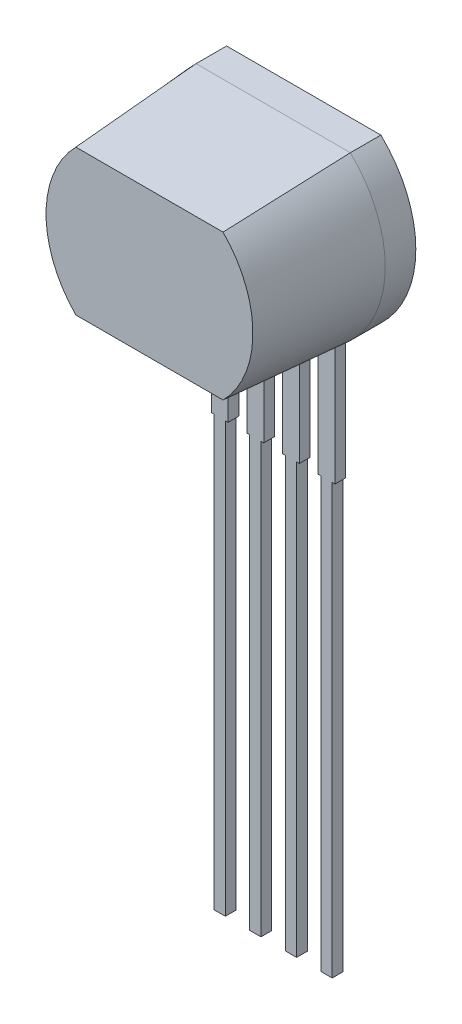
from build123d import *

# Parameters (mm, degrees)
BOSS_EXTRUDE1_DEPTH           = 4.41
BOSS_EXTRUDE1_DRAFT           = 4
BOSS_EXTRUDE1_OTHER_WAY_DEPTH = 1.09
BOSS_EXTRUDE2_DEPTH           = 0.38
BOSS_EXTRUDE2_2_DEPTH         = 0.38
BOSS_EXTRUDE2_3_DEPTH         = 0.38
BOSS_EXTRUDE2_4_DEPTH         = 0.38
CUT_EXTRUDE1_DEPTH            = 0.01


with BuildPart() as part:
    # Sketch1 → Boss-Extrude1 (with draft: the straight prism first)
    with BuildSketch(Plane.XY):
        with BuildLine():
            ThreePointArc((-2.75, 2.9), (-3.995004537, 0), (-2.75, -2.9))
            Line((-2.75, -2.9), (2.75, -2.9))
            ThreePointArc((2.75, -2.9), (3.995004537, 0), (2.75, 2.9))
            Line((2.75, 2.9), (-2.75, 2.9))
        make_face()
    extrude(amount=BOSS_EXTRUDE1_DEPTH)
    # Boss-Extrude1: the draft: its side faces are tilted about the plane it starts from
    boss_extrude1_sides = [part.faces().sort_by_distance(p)[0] for p in [
        (-3.995004537, 0, 2.205),
        (0, -2.9, 2.205),
        (3.995004537, 0, 2.205),
        (0, 2.9, 2.205),
    ]]
    draft(boss_extrude1_sides, Plane.XY, BOSS_EXTRUDE1_DRAFT)

    # Sketch1 → Boss-Extrude1 other way (add)
    with BuildSketch(Plane.XY):
        with BuildLine():
            ThreePointArc((-2.75, 2.9), (-3.995004537, 0), (-2.75, -2.9))
            Line((-2.75, -2.9), (2.75, -2.9))
            ThreePointArc((2.75, -2.9), (3.995004537, 0), (2.75, 2.9))
            Line((2.75, 2.9), (-2.75, 2.9))
        make_face()
    extrude(amount=-BOSS_EXTRUDE1_OTHER_WAY_DEPTH)

    # Sketch3 → Cut-Extrude1 (cut)
    with BuildSketch(Plane(origin=(0, 0, -1.09), x_dir=(-1, 0, 0), z_dir=(0, 0, -1))):
        Polygon((0.016740004, 2.333243647), (0.505201543, 1.274910314), (0.401954681, 1.274910314), (0.245494344, 1.614119715), (-0.234274953, 1.614119715), (-0.395187413, 1.274910314), (-0.498858287, 1.274910314), (0.003171628, 2.333243647), align=None)
        Polygon((0.008895787, 2.12696193), (-0.182757525, 1.722666724), (0.195460958, 1.722666724), align=None, mode=Mode.SUBTRACT)
        Polygon((-2.073635561, 0.79375), (-1.707289407, 0), (-1.784724553, 0), (-1.902069806, 0.254407051), (-2.261896779, 0.254407051), (-2.382581124, 0), (-2.460334279, 0), (-2.083811843, 0.79375), align=None)
        Polygon((-2.079518724, 0.639038712), (-2.223258708, 0.335817308), (-1.939594846, 0.335817308), align=None, mode=Mode.SUBTRACT)
        Polygon((-1.656407997, 0.712339744), (-1.656407997, 0.79375), (-1.239180433, 0.79375), (-1.239180433, 0.712339744), (-1.412177228, 0.712339744), (-1.412177228, 0), (-1.483411202, 0), (-1.483411202, 0.712339744), align=None)
        with BuildLine():
            Line((-1.198475305, 0.153121244), (-1.131375445, 0.193349359))
            add(Edge.make_bspline(
                [(-1.131375445, 0.193349359), (-1.125134702, 0.182902615), (-1.113177679, 0.162887055), (-1.093231567, 0.135841035), (-1.072563925, 0.112853546), (-1.051021701, 0.094058316), (-1.028736388, 0.0792608), (-1.005562504, 0.068782794), (-0.981578143, 0.062247743), (-0.965255509, 0.061453973), (-0.957106615, 0.061057692)],
                knots=[0, 0, 0, 0, 1.272034388, 2.437168799, 3.508375237, 4.49857839, 5.41946034, 6.295179144, 7.148887113, 8, 8, 8, 8], degree=3))
            add(Edge.make_bspline(
                [(-0.957106615, 0.061057692), (-0.950147273, 0.06125152), (-0.936350362, 0.061635783), (-0.916038925, 0.065328037), (-0.896312695, 0.07100043), (-0.877578236, 0.079124106), (-0.860094052, 0.088952655), (-0.844761819, 0.10082402), (-0.831507076, 0.114115071), (-0.820664651, 0.128942923), (-0.812346143, 0.144889847), (-0.805952585, 0.161258322), (-0.802404506, 0.17830548), (-0.801870028, 0.18978321), (-0.801600305, 0.195575421)],
                knots=[0, 0, 0, 0, 1.095163259, 2.171163733, 3.241058638, 4.321873601, 5.38011039, 6.391990106, 7.366004449, 8.327778327, 9.272591725, 10.192022065, 11.087607919, 12, 12, 12, 12], degree=3))
            add(Edge.make_bspline(
                [(-0.801600305, 0.195575421), (-0.801934657, 0.202184149), (-0.802614347, 0.215618728), (-0.808359165, 0.235439721), (-0.817396405, 0.255055), (-0.825733647, 0.267188323), (-0.830062094, 0.27348758)],
                knots=[0, 0, 0, 0, 0.938893495, 1.908633276, 2.914225137, 4, 4, 4, 4], degree=3))
            add(Edge.make_bspline(
                [(-0.830062094, 0.27348758), (-0.833615965, 0.278033913), (-0.841076874, 0.287578371), (-0.853903309, 0.301785416), (-0.868954196, 0.31643995), (-0.885714467, 0.332101558), (-0.904794649, 0.348041826), (-0.925597139, 0.365020882), (-0.94865305, 0.382393025), (-0.964822757, 0.394043589), (-0.97316606, 0.400055088)],
                knots=[0, 0, 0, 0, 0.722233717, 1.516239348, 2.393582979, 3.351407094, 4.387010283, 5.505090956, 6.712668013, 8, 8, 8, 8], degree=3))
            add(Edge.make_bspline(
                [(-0.97316606, 0.400055088), (-0.981517216, 0.406003357), (-0.997483991, 0.417375994), (-1.019812991, 0.434254359), (-1.039780217, 0.449685736), (-1.057296923, 0.463815396), (-1.072355403, 0.476645255), (-1.085074319, 0.488052109), (-1.095129671, 0.498344452), (-1.100721204, 0.505021328), (-1.103231665, 0.508019081)],
                knots=[0, 0, 0, 0, 1.452282411, 2.77665338, 3.964542531, 5.026858415, 5.96415736, 6.766646006, 7.446254459, 8, 8, 8, 8], degree=3))
            add(Edge.make_bspline(
                [(-1.103231665, 0.508019081), (-1.106740617, 0.512691101), (-1.113641443, 0.521879257), (-1.122750519, 0.536240431), (-1.130492793, 0.550941421), (-1.136562108, 0.566021733), (-1.141673, 0.581269655), (-1.145110602, 0.596884134), (-1.147263116, 0.612795106), (-1.147483548, 0.623502453), (-1.147593894, 0.62886243)],
                knots=[0, 0, 0, 0, 1.068054152, 2.10047183, 3.106115577, 4.101338837, 5.06977816, 6.043150881, 7.020423561, 8, 8, 8, 8], degree=3))
            add(Edge.make_bspline(
                [(-1.147593894, 0.62886243), (-1.147297892, 0.637260254), (-1.146712213, 0.653876404), (-1.141759096, 0.678149467), (-1.133941136, 0.701323887), (-1.122988545, 0.72317023), (-1.108869467, 0.743119658), (-1.092530469, 0.761401645), (-1.07306965, 0.776770592), (-1.05171718, 0.790199041), (-1.028345467, 0.800709634), (-1.003854673, 0.808638285), (-0.978205873, 0.813130742), (-0.960833376, 0.81377544), (-0.952018474, 0.814102564)],
                knots=[0, 0, 0, 0, 1.005424448, 1.989358655, 2.955360095, 3.929531133, 4.905563448, 5.876582895, 6.856512386, 7.866279853, 8.892233794, 9.918561126, 10.94386622, 12, 12, 12, 12], degree=3))
            add(Edge.make_bspline(
                [(-0.952018474, 0.814102564), (-0.942664901, 0.81377995), (-0.92406363, 0.813138373), (-0.896702112, 0.807560004), (-0.870358521, 0.798329673), (-0.849166923, 0.787854745), (-0.832581457, 0.777392799), (-0.819932998, 0.767863303), (-0.807115648, 0.75689252), (-0.794026018, 0.744451226), (-0.780885904, 0.730425267), (-0.767500228, 0.7149107), (-0.753837689, 0.698002338), (-0.745048413, 0.685931782), (-0.740542612, 0.67974384)],
                knots=[0, 0, 0, 0, 1.286793592, 2.559021753, 3.825965368, 5.121522368, 5.803751409, 6.523245864, 7.299691795, 8.125521123, 9.008227632, 9.944561021, 10.946284179, 12, 12, 12, 12], degree=3))
            Line((-0.740542612, 0.67974384), (-0.804939397, 0.630929487))
            add(Edge.make_bspline(
                [(-0.804939397, 0.630929487), (-0.80882785, 0.635938887), (-0.8163161, 0.645585819), (-0.827684752, 0.659095742), (-0.83840007, 0.671436622), (-0.848957036, 0.682155678), (-0.858798091, 0.691839912), (-0.868349635, 0.700131142), (-0.877474211, 0.707110608), (-0.888976082, 0.714559058), (-0.90342635, 0.721942408), (-0.9215657, 0.728190145), (-0.940521873, 0.731944597), (-0.953432701, 0.732441005), (-0.959968694, 0.732692308)],
                knots=[0, 0, 0, 0, 1.181633172, 2.275549214, 3.290209073, 4.226197932, 5.078386478, 5.862611352, 6.581680152, 7.217281963, 8.414376989, 9.595101626, 10.782541182, 12, 12, 12, 12], degree=3))
            add(Edge.make_bspline(
                [(-0.959968694, 0.732692308), (-0.968168477, 0.732417511), (-0.983980985, 0.731887593), (-1.006430557, 0.726100025), (-1.026635786, 0.716987353), (-1.043996814, 0.70421592), (-1.05845145, 0.689084552), (-1.06890751, 0.671672205), (-1.075200851, 0.652444767), (-1.07596881, 0.639032284), (-1.07635992, 0.632201522)],
                knots=[0, 0, 0, 0, 1.14458467, 2.207223713, 3.21896685, 4.227309161, 5.202851033, 6.127160689, 7.046193047, 8, 8, 8, 8], degree=3))
            add(Edge.make_bspline(
                [(-1.07635992, 0.632201522), (-1.076270765, 0.627948955), (-1.076092308, 0.619436866), (-1.07360338, 0.606861276), (-1.070405854, 0.594317454), (-1.065338864, 0.581861797), (-1.05834359, 0.569276469), (-1.049157595, 0.556344754), (-1.037588504, 0.54295267), (-1.028726396, 0.534242426), (-1.02404747, 0.52964368)],
                knots=[0, 0, 0, 0, 0.858281714, 1.717966888, 2.583508476, 3.4729293, 4.427298488, 5.488583878, 6.674047936, 8, 8, 8, 8], degree=3))
            add(Edge.make_bspline(
                [(-1.02404747, 0.52964368), (-1.02230998, 0.52809314), (-1.018182102, 0.524409413), (-1.010635598, 0.518378663), (-1.000669999, 0.510939463), (-0.988545535, 0.501734839), (-0.974038651, 0.491057436), (-0.957147752, 0.479043778), (-0.938061119, 0.465303861), (-0.924517041, 0.455697776), (-0.917355513, 0.45061849)],
                knots=[0, 0, 0, 0, 0.420754252, 0.999615792, 1.744751191, 2.668019286, 3.750313428, 4.999500688, 6.413464383, 8, 8, 8, 8], degree=3))
            add(Edge.make_bspline(
                [(-0.917355513, 0.45061849), (-0.908740851, 0.444349824), (-0.892059751, 0.432211422), (-0.868324907, 0.413974295), (-0.846804347, 0.396138104), (-0.827422513, 0.378816754), (-0.809987928, 0.362141633), (-0.794694017, 0.345912126), (-0.781384943, 0.330244505), (-0.767056799, 0.31015751), (-0.752416007, 0.285487515), (-0.739842665, 0.255261914), (-0.731914612, 0.22491882), (-0.730877857, 0.204524698), (-0.73036633, 0.19446239)],
                knots=[0, 0, 0, 0, 1.163667725, 2.253281268, 3.268753668, 4.215851969, 5.092017293, 5.902905408, 6.650798638, 7.335211899, 8.59617414, 9.77448103, 10.901945474, 12, 12, 12, 12], degree=3))
            add(Edge.make_bspline(
                [(-0.73036633, 0.19446239), (-0.73051536, 0.187346225), (-0.730810525, 0.173252086), (-0.734203446, 0.152556738), (-0.739174513, 0.132456523), (-0.746666886, 0.113199896), (-0.755811602, 0.094434566), (-0.767415376, 0.076652774), (-0.780865512, 0.059460966), (-0.796294598, 0.043317567), (-0.813177865, 0.028497983), (-0.831022203, 0.015315142), (-0.849856818, 0.004323219), (-0.869579537, -0.004646347), (-0.890194888, -0.011661627), (-0.911695939, -0.016744545), (-0.934118132, -0.019864144), (-0.949358241, -0.02018794), (-0.957106615, -0.020352564)],
                knots=[0, 0, 0, 0, 0.983748083, 1.948392443, 2.894712957, 3.844097841, 4.80183111, 5.778335162, 6.776009319, 7.81870978, 8.863265674, 9.881300176, 10.883814829, 11.87499822, 12.874611388, 13.892143829, 14.928324115, 16, 16, 16, 16], degree=3))
            add(Edge.make_bspline(
                [(-0.957106615, -0.020352564), (-0.963101773, -0.020236635), (-0.975016586, -0.020006238), (-0.992639987, -0.017969412), (-1.009907358, -0.015087622), (-1.026602025, -0.010512432), (-1.042939081, -0.004961403), (-1.058847472, 0.00187354), (-1.074334907, 0.010064406), (-1.089488181, 0.019429527), (-1.104268752, 0.030328337), (-1.118537989, 0.043022327), (-1.132764072, 0.057161397), (-1.146527106, 0.073129507), (-1.16010548, 0.090668679), (-1.173231477, 0.109943012), (-1.186176795, 0.130847519), (-1.194299231, 0.145557993), (-1.198475305, 0.153121244)],
                knots=[0, 0, 0, 0, 0.915332311, 1.819136955, 2.706846663, 3.586547465, 4.459518054, 5.340707479, 6.227863349, 7.133153174, 8.059268498, 9.028702269, 10.047606654, 11.120612155, 12.245963614, 13.433783089, 14.680604001, 16, 16, 16, 16], degree=3))
        make_face()
        with BuildLine():
            Line((-0.272433638, 0.814102564), (-0.217577118, 0.77101237))
            Line((-0.217577118, 0.77101237), (-0.42730393, 0.450300481))
            add(Edge.make_bspline(
                [(-0.42730393, 0.450300481), (-0.413340671, 0.452526124), (-0.386103755, 0.456867493), (-0.358534346, 0.45758367), (-0.345098652, 0.457932692)],
                knots=[0, 0, 0, 0, 1.025318673, 2, 2, 2, 2], degree=3))
            add(Edge.make_bspline(
                [(-0.345098652, 0.457932692), (-0.337031318, 0.45771586), (-0.321151011, 0.457289032), (-0.297835897, 0.454004301), (-0.275431978, 0.448827892), (-0.254032112, 0.441282219), (-0.233559489, 0.431643293), (-0.213896625, 0.420091085), (-0.195413133, 0.406029082), (-0.177870991, 0.39032078), (-0.161944488, 0.372922464), (-0.147843847, 0.354461803), (-0.135999557, 0.334958032), (-0.126389757, 0.314421028), (-0.1189274, 0.29288245), (-0.113487345, 0.270369854), (-0.110271616, 0.246867717), (-0.109834942, 0.230884273), (-0.109613125, 0.222765174)],
                knots=[0, 0, 0, 0, 1.04369286, 2.054478336, 3.041073146, 4.015093852, 4.984733326, 5.965804835, 6.960378782, 7.985147595, 9.009457201, 10.008161701, 10.986880575, 11.956520048, 12.937015923, 13.931873656, 14.949455224, 16, 16, 16, 16], degree=3))
            add(Edge.make_bspline(
                [(-0.109613125, 0.222765174), (-0.109935865, 0.211657277), (-0.110570941, 0.189799564), (-0.116899123, 0.157964133), (-0.126732471, 0.127635509), (-0.140788089, 0.099297914), (-0.158246594, 0.072990189), (-0.179536691, 0.049679914), (-0.203903339, 0.028890459), (-0.231454809, 0.011505833), (-0.261105446, -0.002691645), (-0.292254917, -0.01288912), (-0.324600716, -0.019167335), (-0.346554618, -0.019954418), (-0.35766, -0.020352564)],
                knots=[0, 0, 0, 0, 1.031375318, 2.029502543, 3.004789286, 3.987476834, 4.960371455, 5.9300674, 6.912260825, 7.929083631, 8.949397511, 9.960523116, 10.96833055, 12, 12, 12, 12], degree=3))
            add(Edge.make_bspline(
                [(-0.35766, -0.020352564), (-0.368340859, -0.020005989), (-0.389497771, -0.019319484), (-0.420620208, -0.013203995), (-0.450524856, -0.003291848), (-0.479002198, 0.01036389), (-0.505382051, 0.027612731), (-0.528982651, 0.048377748), (-0.549686321, 0.072215073), (-0.56691628, 0.099121009), (-0.5805821, 0.12803391), (-0.590830529, 0.158182158), (-0.59681682, 0.189455904), (-0.597653332, 0.210656091), (-0.598074664, 0.221334135)],
                knots=[0, 0, 0, 0, 1.012016664, 2.004627821, 2.994792927, 3.992885782, 4.990978636, 5.973936114, 6.964471063, 7.975201453, 8.993600317, 9.990122807, 10.98767138, 12, 12, 12, 12], degree=3))
            add(Edge.make_bspline(
                [(-0.598074664, 0.221334135), (-0.597806729, 0.229508531), (-0.597259657, 0.246199087), (-0.593439817, 0.271477536), (-0.587301908, 0.297342692), (-0.580427977, 0.319285161), (-0.573165026, 0.337260542), (-0.567120611, 0.351752941), (-0.559597223, 0.366666613), (-0.551575045, 0.382512955), (-0.542331969, 0.39888358), (-0.532281813, 0.416052091), (-0.521146714, 0.433745442), (-0.513340713, 0.44575243), (-0.509350205, 0.451890525)],
                knots=[0, 0, 0, 0, 1.173818275, 2.396712641, 3.66331629, 4.989737886, 5.693666774, 6.447286557, 7.243889047, 8.091586357, 8.998013824, 9.943181721, 10.948533338, 12, 12, 12, 12], degree=3))
            Line((-0.509350205, 0.451890525), (-0.272433638, 0.814102564))
        make_face()
        with BuildLine():
            add(Edge.make_bspline(
                [(-0.360045066, 0.376522436), (-0.366091683, 0.376345987), (-0.377902481, 0.37600133), (-0.395230591, 0.373999889), (-0.411630203, 0.370230922), (-0.427318589, 0.365430701), (-0.442002443, 0.358830543), (-0.455788483, 0.35081326), (-0.468730022, 0.341374171), (-0.480691506, 0.330647), (-0.491536322, 0.318902214), (-0.500875615, 0.306322519), (-0.508931587, 0.293211083), (-0.515481571, 0.279458357), (-0.520581999, 0.265069598), (-0.524271406, 0.250110982), (-0.526324668, 0.234482202), (-0.526666259, 0.223883938), (-0.526840689, 0.218472055)],
                knots=[0, 0, 0, 0, 1.129588631, 2.206414736, 3.251139165, 4.268635594, 5.265702196, 6.250456724, 7.242448911, 8.251968645, 9.246821453, 10.222880186, 11.173611482, 12.116736599, 13.062300278, 14.020270554, 14.989073742, 16, 16, 16, 16], degree=3))
            add(Edge.make_bspline(
                [(-0.526840689, 0.218472055), (-0.526698639, 0.213108578), (-0.526420101, 0.202591597), (-0.523890914, 0.187093247), (-0.520027601, 0.172178705), (-0.514280761, 0.157924861), (-0.507425735, 0.144114446), (-0.498375777, 0.131247693), (-0.488348042, 0.118543142), (-0.476361525, 0.106976737), (-0.463497476, 0.096214252), (-0.449753989, 0.086807123), (-0.435430213, 0.078759366), (-0.420332765, 0.072452206), (-0.404675846, 0.067275984), (-0.388329006, 0.06363347), (-0.371280876, 0.061574137), (-0.359732508, 0.0612321), (-0.353843894, 0.061057692)],
                knots=[0, 0, 0, 0, 0.989467248, 1.94019797, 2.891935182, 3.827694429, 4.772920941, 5.730924762, 6.725747692, 7.756678648, 8.79901574, 9.819492441, 10.826891316, 11.826466727, 12.835195252, 13.867842842, 14.912794438, 16, 16, 16, 16], degree=3))
            add(Edge.make_bspline(
                [(-0.353843894, 0.061057692), (-0.34795529, 0.061232114), (-0.336406941, 0.061574177), (-0.319358674, 0.063633316), (-0.303012341, 0.067276549), (-0.28735358, 0.072450159), (-0.272262934, 0.07876696), (-0.257951684, 0.086757056), (-0.24433817, 0.096272104), (-0.231465677, 0.106958344), (-0.219529052, 0.118608973), (-0.209260812, 0.131134285), (-0.200488007, 0.144218437), (-0.193359182, 0.157870458), (-0.18767564, 0.172187324), (-0.183792735, 0.187090938), (-0.181268772, 0.202592201), (-0.180989515, 0.213108782), (-0.1808471, 0.218472055)],
                knots=[0, 0, 0, 0, 1.087397944, 2.132534446, 3.165364764, 4.174271784, 5.174024072, 6.181601208, 7.194203697, 8.236725232, 9.267838612, 10.269026844, 11.221737037, 12.171628256, 13.107553087, 14.05945871, 15.010357665, 16, 16, 16, 16], degree=3))
            add(Edge.make_bspline(
                [(-0.1808471, 0.218472055), (-0.180971898, 0.223890998), (-0.181216837, 0.23452662), (-0.18398724, 0.250103991), (-0.187829528, 0.2651456), (-0.193631394, 0.279556914), (-0.201168968, 0.293281062), (-0.210350026, 0.306387371), (-0.220970984, 0.318976325), (-0.233239533, 0.330670033), (-0.246594997, 0.341362317), (-0.260795317, 0.350801038), (-0.27565159, 0.358766881), (-0.291148752, 0.365413313), (-0.30746437, 0.370209711), (-0.324335036, 0.373986429), (-0.341976525, 0.375996208), (-0.353945506, 0.376344792), (-0.360045066, 0.376522436)],
                knots=[0, 0, 0, 0, 0.978206639, 1.919901502, 2.851605144, 3.780102724, 4.718870031, 5.675451981, 6.667674623, 7.690630536, 8.733308323, 9.756129687, 10.767539656, 11.776269907, 12.797430371, 13.836405707, 14.897401972, 16, 16, 16, 16], degree=3))
        make_face(mode=Mode.SUBTRACT)
        with BuildLine():
            add(Edge.make_bspline(
                [(-0.028202869, 0.396556991), (-0.028128479, 0.409279077), (-0.027983976, 0.433991913), (-0.026376423, 0.470002002), (-0.023705944, 0.503784067), (-0.020046218, 0.535339727), (-0.015592605, 0.564677127), (-0.009647307, 0.591717866), (-0.002886189, 0.616587099), (0.004949812, 0.63936592), (0.013791686, 0.660361221), (0.02341517, 0.679961222), (0.034202186, 0.698136267), (0.045536236, 0.715176445), (0.057876116, 0.730802818), (0.070870663, 0.745236065), (0.085027053, 0.75814261), (0.099864057, 0.769900611), (0.115516005, 0.780207902), (0.131536752, 0.789286755), (0.148036571, 0.797042796), (0.165060509, 0.803141163), (0.182455553, 0.808178266), (0.200282513, 0.811622902), (0.218570822, 0.813790272), (0.230915094, 0.813997479), (0.237175487, 0.814102564)],
                knots=[0, 0, 0, 0, 1.646270934, 3.197905019, 4.663502075, 6.030701355, 7.308322542, 8.50163776, 9.611534131, 10.641858119, 11.616356847, 12.558055219, 13.465016945, 14.349605745, 15.204443733, 16.039544428, 16.859896111, 17.680448484, 18.487036065, 19.28249412, 20.06191084, 20.843045899, 21.620316918, 22.403196591, 23.190181807, 24, 24, 24, 24], degree=3))
            add(Edge.make_bspline(
                [(0.237175487, 0.814102564), (0.243488175, 0.813991935), (0.256042127, 0.813771927), (0.274602355, 0.81165739), (0.292733801, 0.808148761), (0.310359165, 0.803177397), (0.327623224, 0.797009806), (0.344390945, 0.789279335), (0.36076648, 0.780280734), (0.376489599, 0.769707105), (0.391732913, 0.757918267), (0.406122005, 0.744591734), (0.419658183, 0.729862065), (0.432511333, 0.713886857), (0.444316798, 0.696359703), (0.455559345, 0.67758545), (0.465622289, 0.657235772), (0.475313902, 0.635650201), (0.483679344, 0.612231479), (0.491223653, 0.587111613), (0.497319419, 0.559993896), (0.502396986, 0.531020605), (0.506330561, 0.500085336), (0.509195464, 0.467254404), (0.510708824, 0.432506208), (0.510993826, 0.408748625), (0.51114008, 0.396556991)],
                knots=[0, 0, 0, 0, 0.810914788, 1.612654377, 2.396697861, 3.181598691, 3.963628158, 4.749916497, 5.551656086, 6.361998678, 7.18212741, 8.025565596, 8.878627764, 9.750805457, 10.657531673, 11.591944965, 12.560506719, 13.57287815, 14.630710178, 15.753379473, 16.941251878, 18.199788006, 19.531962791, 20.947069417, 22.433333509, 24, 24, 24, 24], degree=3))
            add(Edge.make_bspline(
                [(0.51114008, 0.396556991), (0.51099231, 0.384418533), (0.510704386, 0.360767244), (0.509212429, 0.326175398), (0.506273597, 0.293518698), (0.502597403, 0.262718826), (0.497505845, 0.233903973), (0.491245388, 0.206974428), (0.484294333, 0.181813898), (0.475713942, 0.158628503), (0.466322584, 0.137094809), (0.456104709, 0.116986366), (0.445157802, 0.098125439), (0.433231426, 0.080662996), (0.420519313, 0.064475337), (0.406749386, 0.049848197), (0.392309807, 0.036429134), (0.377021634, 0.024488497), (0.3610533, 0.014037122), (0.344734009, 0.004690409), (0.327774206, -0.002846291), (0.310558233, -0.009317631), (0.292839836, -0.014261662), (0.274641101, -0.017680197), (0.256054597, -0.020077741), (0.243490314, -0.020260639), (0.237175487, -0.020352564)],
                knots=[0, 0, 0, 0, 1.561518951, 3.042555995, 4.452378317, 5.7783523, 7.031515105, 8.214008947, 9.334062868, 10.386615937, 11.391082383, 12.354592575, 13.286541444, 14.194233754, 15.072674879, 15.931287219, 16.775624067, 17.606195743, 18.42308326, 19.229000347, 20.022332153, 20.807536673, 21.593273796, 22.3848459, 23.188221202, 24, 24, 24, 24], degree=3))
            add(Edge.make_bspline(
                [(0.237175487, -0.020352564), (0.230915268, -0.020246801), (0.218571338, -0.020038258), (0.200280521, -0.017880679), (0.182527181, -0.014411878), (0.165223713, -0.009554898), (0.148281343, -0.003609748), (0.131930935, 0.00413582), (0.115990692, 0.013056225), (0.100503143, 0.023215187), (0.085759314, 0.034854211), (0.071676237, 0.047727541), (0.058607706, 0.062156422), (0.046444259, 0.077913022), (0.034884064, 0.094852382), (0.024250224, 0.113205781), (0.014414334, 0.132900445), (0.005423757, 0.154063614), (-0.002547458, 0.177004106), (-0.009588634, 0.201984366), (-0.015148095, 0.229224877), (-0.01990673, 0.258506851), (-0.023744938, 0.289956117), (-0.026365294, 0.323589749), (-0.027984842, 0.359386788), (-0.028128867, 0.383940826), (-0.028202869, 0.396556991)],
                knots=[0, 0, 0, 0, 0.810891512, 1.598919785, 2.382837074, 3.152667961, 3.926044502, 4.706494248, 5.493654104, 6.291793342, 7.103789334, 7.925228297, 8.761435821, 9.622817696, 10.50288917, 11.416980706, 12.369136599, 13.353924996, 14.394355917, 15.514179734, 16.714354668, 17.994756427, 19.357759367, 20.818452758, 22.365282078, 24, 24, 24, 24], degree=3))
        make_face()
        with BuildLine():
            add(Edge.make_bspline(
                [(0.043031106, 0.396875), (0.043058194, 0.386273063), (0.043110769, 0.365696785), (0.044484228, 0.335796617), (0.046355263, 0.307908703), (0.048768557, 0.281997633), (0.05235244, 0.258151112), (0.056368087, 0.236205131), (0.061254886, 0.216275829), (0.067036792, 0.19822645), (0.073622444, 0.181750679), (0.080812881, 0.166419689), (0.088537366, 0.152052375), (0.097182245, 0.138777789), (0.106597268, 0.126552641), (0.116569775, 0.115160552), (0.127471951, 0.105001237), (0.142554049, 0.092816754), (0.162465036, 0.080225807), (0.187552175, 0.069261605), (0.213330555, 0.062371298), (0.230827357, 0.061495053), (0.239560553, 0.061057692)],
                knots=[0, 0, 0, 0, 1.459021318, 2.831673884, 4.118529203, 5.306027144, 6.411944654, 7.436330062, 8.375795394, 9.233974572, 10.042671642, 10.816086306, 11.563610507, 12.285937304, 12.993564865, 13.685989202, 14.367179055, 15.041617293, 16.353048772, 17.594441528, 18.799311195, 20, 20, 20, 20], degree=3))
            add(Edge.make_bspline(
                [(0.239560553, 0.061057692), (0.248350239, 0.061420046), (0.265911464, 0.062144006), (0.291568593, 0.069128719), (0.316476529, 0.079667347), (0.335996415, 0.092128656), (0.350846921, 0.103995974), (0.361487024, 0.114113939), (0.371252881, 0.125443216), (0.38051528, 0.137666806), (0.389010464, 0.151018245), (0.396735497, 0.165433329), (0.403784756, 0.180952089), (0.407800914, 0.191785583), (0.409854273, 0.197324469)],
                knots=[0, 0, 0, 0, 1.353760809, 2.704726607, 4.075137775, 5.516104923, 6.260822281, 7.007110065, 7.778089737, 8.566572457, 9.372053459, 10.217411131, 11.088608312, 12, 12, 12, 12], degree=3))
            add(Edge.make_bspline(
                [(0.409854273, 0.197324469), (0.412247263, 0.204406928), (0.417106059, 0.218787357), (0.423368015, 0.241094828), (0.428299561, 0.26449974), (0.432736253, 0.288862222), (0.435764535, 0.31436194), (0.438201986, 0.340919995), (0.439637695, 0.368556411), (0.439815665, 0.387333132), (0.439906106, 0.396875)],
                knots=[0, 0, 0, 0, 0.884706709, 1.796334032, 2.740027952, 3.714592787, 4.726048262, 5.777819803, 6.87074269, 8, 8, 8, 8], degree=3))
            add(Edge.make_bspline(
                [(0.439906106, 0.396875), (0.439781331, 0.406415324), (0.439537244, 0.425078239), (0.43860425, 0.45241004), (0.436194975, 0.478369693), (0.433519104, 0.503069033), (0.429573662, 0.526371333), (0.42531966, 0.54847167), (0.419604385, 0.569096249), (0.413499364, 0.588567976), (0.406512007, 0.606665624), (0.398820403, 0.623473572), (0.390605825, 0.639072965), (0.381683567, 0.653421004), (0.372159546, 0.666581955), (0.361782388, 0.678291944), (0.350963718, 0.688913899), (0.335810534, 0.701038446), (0.315972615, 0.71340092), (0.291287977, 0.724777798), (0.265599813, 0.731311107), (0.248234048, 0.732232239), (0.239560553, 0.732692308)],
                knots=[0, 0, 0, 0, 1.31362396, 2.569729283, 3.763502607, 4.902122613, 5.988968491, 7.01645872, 7.998833611, 8.933434873, 9.825090667, 10.667526885, 11.477055099, 12.250526234, 12.991942729, 13.710640831, 14.402115721, 15.076753259, 16.378508321, 17.609869233, 18.806226677, 20, 20, 20, 20], degree=3))
            add(Edge.make_bspline(
                [(0.239560553, 0.732692308), (0.230781543, 0.732231605), (0.213207532, 0.731309359), (0.18725237, 0.724802139), (0.162372991, 0.713459913), (0.14258753, 0.7009975), (0.127423779, 0.689127919), (0.116746097, 0.678834919), (0.106734375, 0.667575858), (0.097511522, 0.655238281), (0.088873417, 0.641979171), (0.080940223, 0.627694219), (0.073792543, 0.612311034), (0.067196585, 0.595842664), (0.061397042, 0.577794843), (0.056613233, 0.557890089), (0.052193847, 0.53601391), (0.049065278, 0.512038236), (0.046284033, 0.486120676), (0.044496656, 0.458163141), (0.043106174, 0.428212826), (0.04305663, 0.40753016), (0.043031106, 0.396875)],
                knots=[0, 0, 0, 0, 1.207732386, 2.417664972, 3.655092373, 4.956220595, 5.625982001, 6.301752483, 6.994047911, 7.697131622, 8.419323945, 9.170223765, 9.943494443, 10.752040957, 11.610060368, 12.549350801, 13.567764191, 14.679664412, 15.874934091, 17.154273443, 18.533957287, 20, 20, 20, 20], degree=3))
        make_face(mode=Mode.SUBTRACT)
        with BuildLine():
            Line((1.081011875, 0.79375), (1.081011875, 0.712339744))
            Line((1.081011875, 0.712339744), (0.811022392, 0.712339744))
            Line((0.811022392, 0.712339744), (0.768250206, 0.503566957))
            add(Edge.make_bspline(
                [(0.768250206, 0.503566957), (0.776653949, 0.505887037), (0.792934872, 0.510381824), (0.816965055, 0.515372418), (0.839777929, 0.518380831), (0.854581451, 0.518791611), (0.861744797, 0.518990385)],
                knots=[0, 0, 0, 0, 1.100273476, 2.13160584, 3.095893838, 4, 4, 4, 4], degree=3))
            add(Edge.make_bspline(
                [(0.861744797, 0.518990385), (0.870608431, 0.518798538), (0.88803655, 0.518421321), (0.913536097, 0.514799134), (0.937877664, 0.50909776), (0.961010344, 0.501132928), (0.982976933, 0.490948042), (1.003575327, 0.478225377), (1.023114711, 0.463363353), (1.041244549, 0.446276181), (1.057692026, 0.427470743), (1.072153241, 0.407251011), (1.084436543, 0.385813488), (1.0943155, 0.36295335), (1.10220409, 0.338923328), (1.107454632, 0.313470581), (1.110950921, 0.286835026), (1.111341534, 0.268623096), (1.111540721, 0.259336188)],
                knots=[0, 0, 0, 0, 1.052922333, 2.070308379, 3.05430497, 4.020497103, 4.973039431, 5.925935799, 6.892292201, 7.88610001, 8.88166317, 9.857072816, 10.836096531, 11.812156883, 12.81219415, 13.836441305, 14.89672472, 16, 16, 16, 16], degree=3))
            add(Edge.make_bspline(
                [(1.111540721, 0.259336188), (1.111389891, 0.252867756), (1.111090271, 0.240018307), (1.109566591, 0.220935604), (1.106632955, 0.20225689), (1.102694204, 0.183979687), (1.097581905, 0.166138597), (1.091393138, 0.148682554), (1.083819396, 0.131720206), (1.075511923, 0.115091054), (1.066157811, 0.099171035), (1.0557759, 0.084282783), (1.044807297, 0.070202955), (1.033005054, 0.057082555), (1.020259472, 0.045007799), (1.006724908, 0.033907028), (0.992509362, 0.023592512), (0.977392906, 0.014482939), (0.961712378, 0.006100269), (0.945241336, -0.000776676), (0.928354713, -0.006924957), (0.910809464, -0.011825689), (0.892645332, -0.01566575), (0.873832374, -0.018273922), (0.854469258, -0.020173579), (0.841344032, -0.020292495), (0.834714048, -0.020352564)],
                knots=[0, 0, 0, 0, 1.056347294, 2.098418968, 3.122841568, 4.141288669, 5.149314143, 6.15115421, 7.162517403, 8.180376062, 9.185164535, 10.17417709, 11.141909838, 12.097768115, 13.052685741, 14.0056014, 14.954263652, 15.917497458, 16.885230207, 17.854509472, 18.828990115, 19.81800267, 20.826176721, 21.857883937, 22.917946725, 24, 24, 24, 24], degree=3))
            add(Edge.make_bspline(
                [(0.834714048, -0.020352564), (0.826805082, -0.020195892), (0.811245126, -0.019887658), (0.788448497, -0.016663109), (0.766515007, -0.012044863), (0.745621216, -0.005096995), (0.725579876, 0.003608695), (0.706660795, 0.01461147), (0.688380556, 0.027079945), (0.671482291, 0.041793882), (0.655798672, 0.057876546), (0.641759161, 0.075329439), (0.629255653, 0.093864509), (0.618488378, 0.113571769), (0.609304005, 0.134399436), (0.602088821, 0.156425545), (0.596265337, 0.17953501), (0.593801668, 0.195444824), (0.592550336, 0.203525641)],
                knots=[0, 0, 0, 0, 1.0467383, 2.05933395, 3.04377827, 4.011590433, 4.970194871, 5.932262533, 6.905835911, 7.896367577, 8.894135286, 9.877477877, 10.858688626, 11.851381753, 12.8477658, 13.868841284, 14.917554742, 16, 16, 16, 16], degree=3))
            Line((0.592550336, 0.203525641), (0.663784311, 0.203525641))
            add(Edge.make_bspline(
                [(0.663784311, 0.203525641), (0.665537037, 0.195956338), (0.668905875, 0.181407719), (0.676300393, 0.160967218), (0.685341404, 0.142751965), (0.696092033, 0.126521006), (0.708916772, 0.112367537), (0.723551124, 0.099754382), (0.739958554, 0.08837538), (0.75819059, 0.078890573), (0.777424985, 0.07080141), (0.79755612, 0.065414865), (0.818035856, 0.061627341), (0.831887558, 0.061248209), (0.838848163, 0.061057692)],
                knots=[0, 0, 0, 0, 1.136247022, 2.183929868, 3.172523383, 4.106158343, 5.02341133, 5.958108904, 6.928429099, 7.938127109, 8.96079061, 9.975095812, 10.982467395, 12, 12, 12, 12], degree=3))
            add(Edge.make_bspline(
                [(0.838848163, 0.061057692), (0.84564231, 0.061243833), (0.859020042, 0.061610346), (0.878707624, 0.064431336), (0.897715186, 0.068775999), (0.915855176, 0.075277913), (0.933445025, 0.083180197), (0.950039791, 0.093320938), (0.966119551, 0.104991335), (0.981184503, 0.118361856), (0.994982021, 0.133096055), (1.007173141, 0.148852535), (1.017327905, 0.165661177), (1.025885462, 0.183230981), (1.032383621, 0.201754511), (1.037019343, 0.221144956), (1.039741466, 0.241450211), (1.04011593, 0.255299858), (1.040306747, 0.262357272)],
                knots=[0, 0, 0, 0, 1.027316725, 2.022795036, 3.002884548, 3.971462791, 4.93288096, 5.914575861, 6.907176829, 7.935150275, 8.956128384, 9.956726525, 10.942570165, 11.921478529, 12.907843606, 13.90538589, 14.932640048, 16, 16, 16, 16], degree=3))
            add(Edge.make_bspline(
                [(1.040306747, 0.262357272), (1.040157413, 0.268724451), (1.039865113, 0.281187299), (1.03747693, 0.29942069), (1.033322903, 0.316672969), (1.02755713, 0.333027447), (1.020236599, 0.34849955), (1.011290739, 0.363105244), (1.000551664, 0.376652024), (0.988284397, 0.389146228), (0.97484552, 0.400677119), (0.960003814, 0.410506939), (0.944069866, 0.418776434), (0.927235653, 0.425912927), (0.909100757, 0.431038453), (0.890024306, 0.434886527), (0.869800303, 0.437112511), (0.855973022, 0.437421368), (0.84886544, 0.437580128)],
                knots=[0, 0, 0, 0, 1.045622112, 2.046656509, 3.013763289, 3.955457236, 4.890082067, 5.820317437, 6.762574623, 7.722996705, 8.69280354, 9.665887285, 10.63943826, 11.638615906, 12.663482002, 13.728887084, 14.832589034, 16, 16, 16, 16], degree=3))
            add(Edge.make_bspline(
                [(0.84886544, 0.437580128), (0.842712987, 0.437448458), (0.830009731, 0.437176594), (0.810523662, 0.43517487), (0.790046789, 0.431945602), (0.768657609, 0.427503721), (0.746291886, 0.421690959), (0.72299682, 0.414725349), (0.698723431, 0.406397324), (0.682368162, 0.400108054), (0.673960593, 0.396875)],
                knots=[0, 0, 0, 0, 0.817624296, 1.688186739, 2.600797293, 3.572016777, 4.590301741, 5.671205678, 6.80286297, 8, 8, 8, 8], degree=3))
            Line((0.673960593, 0.396875), (0.755370849, 0.79375))
            Line((0.755370849, 0.79375), (1.081011875, 0.79375))
        make_face()
        Polygon((1.264184952, 0.79375), (1.335418926, 0.79375), (1.335418926, 0.081410256), (1.640707388, 0.081410256), (1.640707388, 0), (1.264184952, 0), align=None)
        with BuildLine():
            Line((1.691588798, 0.153121244), (1.758688658, 0.193349359))
            add(Edge.make_bspline(
                [(1.758688658, 0.193349359), (1.764929401, 0.182902615), (1.776886424, 0.162887055), (1.796832535, 0.135841035), (1.817500178, 0.112853546), (1.839042402, 0.094058316), (1.861327715, 0.0792608), (1.884501599, 0.068782794), (1.908485959, 0.062247743), (1.924808594, 0.061453973), (1.932957488, 0.061057692)],
                knots=[0, 0, 0, 0, 1.272034388, 2.437168799, 3.508375237, 4.49857839, 5.41946034, 6.295179144, 7.148887113, 8, 8, 8, 8], degree=3))
            add(Edge.make_bspline(
                [(1.932957488, 0.061057692), (1.939916829, 0.06125152), (1.95371374, 0.061635783), (1.974025178, 0.065328037), (1.993751408, 0.07100043), (2.012485867, 0.079124106), (2.029970051, 0.088952655), (2.045302283, 0.10082402), (2.058557027, 0.114115071), (2.069399451, 0.128942923), (2.077717959, 0.144889847), (2.084111517, 0.161258322), (2.087659597, 0.17830548), (2.088194075, 0.18978321), (2.088463798, 0.195575421)],
                knots=[0, 0, 0, 0, 1.095163259, 2.171163733, 3.241058638, 4.321873601, 5.38011039, 6.391990106, 7.366004449, 8.327778327, 9.272591725, 10.192022065, 11.087607919, 12, 12, 12, 12], degree=3))
            add(Edge.make_bspline(
                [(2.088463798, 0.195575421), (2.088129445, 0.202184149), (2.087449755, 0.215618728), (2.081704937, 0.235439721), (2.072667698, 0.255055), (2.064330455, 0.267188323), (2.060002009, 0.27348758)],
                knots=[0, 0, 0, 0, 0.938893495, 1.908633276, 2.914225137, 4, 4, 4, 4], degree=3))
            add(Edge.make_bspline(
                [(2.060002009, 0.27348758), (2.056448138, 0.278033913), (2.048987229, 0.287578371), (2.036160793, 0.301785416), (2.021109907, 0.31643995), (2.004349636, 0.332101558), (1.985269453, 0.348041826), (1.964466964, 0.365020882), (1.941411053, 0.382393025), (1.925241345, 0.394043589), (1.916898043, 0.400055088)],
                knots=[0, 0, 0, 0, 0.722233717, 1.516239348, 2.393582979, 3.351407094, 4.387010283, 5.505090956, 6.712668013, 8, 8, 8, 8], degree=3))
            add(Edge.make_bspline(
                [(1.916898043, 0.400055088), (1.908546886, 0.406003357), (1.892580112, 0.417375994), (1.870251112, 0.434254359), (1.850283885, 0.449685736), (1.83276718, 0.463815396), (1.8177087, 0.476645255), (1.804989783, 0.488052109), (1.794934432, 0.498344452), (1.789342898, 0.505021328), (1.786832438, 0.508019081)],
                knots=[0, 0, 0, 0, 1.452282411, 2.77665338, 3.964542531, 5.026858415, 5.96415736, 6.766646006, 7.446254459, 8, 8, 8, 8], degree=3))
            add(Edge.make_bspline(
                [(1.786832438, 0.508019081), (1.783323485, 0.512691101), (1.77642266, 0.521879257), (1.767313584, 0.536240431), (1.759571309, 0.550941421), (1.753501995, 0.566021733), (1.748391102, 0.581269655), (1.7449535, 0.596884134), (1.742800987, 0.612795106), (1.742580554, 0.623502453), (1.742470208, 0.62886243)],
                knots=[0, 0, 0, 0, 1.068054152, 2.10047183, 3.106115577, 4.101338837, 5.06977816, 6.043150881, 7.020423561, 8, 8, 8, 8], degree=3))
            add(Edge.make_bspline(
                [(1.742470208, 0.62886243), (1.742766211, 0.637260254), (1.74335189, 0.653876404), (1.748305007, 0.678149467), (1.756122967, 0.701323887), (1.767075557, 0.72317023), (1.781194636, 0.743119658), (1.797533633, 0.761401645), (1.816994453, 0.776770592), (1.838346922, 0.790199041), (1.861718635, 0.800709634), (1.88620943, 0.808638285), (1.91185823, 0.813130742), (1.929230726, 0.81377544), (1.938045629, 0.814102564)],
                knots=[0, 0, 0, 0, 1.005424448, 1.989358655, 2.955360095, 3.929531133, 4.905563448, 5.876582895, 6.856512386, 7.866279853, 8.892233794, 9.918561126, 10.94386622, 12, 12, 12, 12], degree=3))
            add(Edge.make_bspline(
                [(1.938045629, 0.814102564), (1.947399202, 0.81377995), (1.966000472, 0.813138373), (1.993361991, 0.807560004), (2.019705582, 0.798329673), (2.04089718, 0.787854745), (2.057482645, 0.777392799), (2.070131104, 0.767863303), (2.082948455, 0.75689252), (2.096038085, 0.744451226), (2.109178199, 0.730425267), (2.122563874, 0.7149107), (2.136226414, 0.698002338), (2.145015689, 0.685931782), (2.14952149, 0.67974384)],
                knots=[0, 0, 0, 0, 1.286793592, 2.559021753, 3.825965368, 5.121522368, 5.803751409, 6.523245864, 7.299691795, 8.125521123, 9.008227632, 9.944561021, 10.946284179, 12, 12, 12, 12], degree=3))
            Line((2.14952149, 0.67974384), (2.085124705, 0.630929487))
            add(Edge.make_bspline(
                [(2.085124705, 0.630929487), (2.081236253, 0.635938887), (2.073748002, 0.645585819), (2.062379351, 0.659095742), (2.051664032, 0.671436622), (2.041107067, 0.682155678), (2.031266011, 0.691839912), (2.021714468, 0.700131142), (2.012589892, 0.707110608), (2.001088021, 0.714559058), (1.986637752, 0.721942408), (1.968498402, 0.728190145), (1.949542229, 0.731944597), (1.936631402, 0.732441005), (1.930095408, 0.732692308)],
                knots=[0, 0, 0, 0, 1.181633172, 2.275549214, 3.290209073, 4.226197932, 5.078386478, 5.862611352, 6.581680152, 7.217281963, 8.414376989, 9.595101626, 10.782541182, 12, 12, 12, 12], degree=3))
            add(Edge.make_bspline(
                [(1.930095408, 0.732692308), (1.921895626, 0.732417511), (1.906083117, 0.731887593), (1.883633546, 0.726100025), (1.863428316, 0.716987353), (1.846067288, 0.70421592), (1.831612652, 0.689084552), (1.821156593, 0.671672205), (1.814863252, 0.652444767), (1.814095292, 0.639032284), (1.813704182, 0.632201522)],
                knots=[0, 0, 0, 0, 1.14458467, 2.207223713, 3.21896685, 4.227309161, 5.202851033, 6.127160689, 7.046193047, 8, 8, 8, 8], degree=3))
            add(Edge.make_bspline(
                [(1.813704182, 0.632201522), (1.813793338, 0.627948955), (1.813971795, 0.619436866), (1.816460722, 0.606861276), (1.819658249, 0.594317454), (1.824725238, 0.581861797), (1.831720512, 0.569276469), (1.840906508, 0.556344754), (1.852475598, 0.54295267), (1.861337706, 0.534242426), (1.866016632, 0.52964368)],
                knots=[0, 0, 0, 0, 0.858281714, 1.717966888, 2.583508476, 3.4729293, 4.427298488, 5.488583878, 6.674047936, 8, 8, 8, 8], degree=3))
            add(Edge.make_bspline(
                [(1.866016632, 0.52964368), (1.867754122, 0.52809314), (1.871882, 0.524409413), (1.879428505, 0.518378663), (1.889394104, 0.510939463), (1.901518567, 0.501734839), (1.916025451, 0.491057436), (1.93291635, 0.479043778), (1.952002984, 0.465303861), (1.965547061, 0.455697776), (1.97270859, 0.45061849)],
                knots=[0, 0, 0, 0, 0.420754252, 0.999615792, 1.744751191, 2.668019286, 3.750313428, 4.999500688, 6.413464383, 8, 8, 8, 8], degree=3))
            add(Edge.make_bspline(
                [(1.97270859, 0.45061849), (1.981323252, 0.444349824), (1.998004352, 0.432211422), (2.021739196, 0.413974295), (2.043259756, 0.396138104), (2.06264159, 0.378816754), (2.080076174, 0.362141633), (2.095370086, 0.345912126), (2.10867916, 0.330244505), (2.123007304, 0.31015751), (2.137648095, 0.285487515), (2.150221437, 0.255261914), (2.158149491, 0.22491882), (2.159186245, 0.204524698), (2.159697772, 0.19446239)],
                knots=[0, 0, 0, 0, 1.163667725, 2.253281268, 3.268753668, 4.215851969, 5.092017293, 5.902905408, 6.650798638, 7.335211899, 8.59617414, 9.77448103, 10.901945474, 12, 12, 12, 12], degree=3))
            add(Edge.make_bspline(
                [(2.159697772, 0.19446239), (2.159548743, 0.187346225), (2.159253578, 0.173252086), (2.155860656, 0.152556738), (2.150889589, 0.132456523), (2.143397217, 0.113199896), (2.1342525, 0.094434566), (2.122648726, 0.076652774), (2.109198591, 0.059460966), (2.093769505, 0.043317567), (2.076886237, 0.028497983), (2.0590419, 0.015315142), (2.040207284, 0.004323219), (2.020484566, -0.004646347), (1.999869214, -0.011661627), (1.978368164, -0.016744545), (1.955945971, -0.019864144), (1.940705862, -0.02018794), (1.932957488, -0.020352564)],
                knots=[0, 0, 0, 0, 0.983748083, 1.948392443, 2.894712957, 3.844097841, 4.80183111, 5.778335162, 6.776009319, 7.81870978, 8.863265674, 9.881300176, 10.883814829, 11.87499822, 12.874611388, 13.892143829, 14.928324115, 16, 16, 16, 16], degree=3))
            add(Edge.make_bspline(
                [(1.932957488, -0.020352564), (1.92696233, -0.020236635), (1.915047516, -0.020006238), (1.897424116, -0.017969412), (1.880156745, -0.015087622), (1.863462077, -0.010512432), (1.847125021, -0.004961403), (1.831216631, 0.00187354), (1.815729195, 0.010064406), (1.800575922, 0.019429527), (1.78579535, 0.030328337), (1.771526114, 0.043022327), (1.757300031, 0.057161397), (1.743536996, 0.073129507), (1.729958622, 0.090668679), (1.716832626, 0.109943012), (1.703887308, 0.130847519), (1.695764871, 0.145557993), (1.691588798, 0.153121244)],
                knots=[0, 0, 0, 0, 0.915332311, 1.819136955, 2.706846663, 3.586547465, 4.459518054, 5.340707479, 6.227863349, 7.133153174, 8.059268498, 9.028702269, 10.047606654, 11.120612155, 12.245963614, 13.433783089, 14.680604001, 16, 16, 16, 16], degree=3))
        make_face()
        with BuildLine():
            Line((3.065386875, 0.658278245), (3.004329182, 0.600400641))
            add(Edge.make_bspline(
                [(3.004329182, 0.600400641), (2.993280435, 0.610794426), (2.971446403, 0.63133415), (2.935850062, 0.657983965), (2.898710809, 0.680813599), (2.860222439, 0.699388763), (2.821338089, 0.714209836), (2.782573884, 0.724761753), (2.744327448, 0.731491061), (2.718889526, 0.73229578), (2.706354924, 0.732692308)],
                knots=[0, 0, 0, 0, 1.08915593, 2.152340314, 3.188132944, 4.216796309, 5.218260357, 6.173443236, 7.099959455, 8, 8, 8, 8], degree=3))
            add(Edge.make_bspline(
                [(2.706354924, 0.732692308), (2.698663554, 0.732598508), (2.683300763, 0.732411151), (2.660481144, 0.730019874), (2.637900853, 0.726580699), (2.615602516, 0.721604595), (2.593542778, 0.715297897), (2.571798361, 0.707409051), (2.550328704, 0.698211701), (2.529336039, 0.687583962), (2.508984175, 0.675909068), (2.489762536, 0.662971274), (2.471548604, 0.649185245), (2.454684722, 0.634205826), (2.439073885, 0.618168705), (2.424344522, 0.601372205), (2.411014671, 0.583357432), (2.398974353, 0.564455835), (2.388233415, 0.544999392), (2.378751809, 0.525175375), (2.370792291, 0.505049537), (2.364494575, 0.484596622), (2.359298766, 0.463974864), (2.355643523, 0.443041472), (2.353582785, 0.421774032), (2.353226327, 0.407532511), (2.353047131, 0.400373097)],
                knots=[0, 0, 0, 0, 1.02818874, 2.053710826, 3.065248034, 4.081641283, 5.106893873, 6.131558223, 7.173050175, 8.228653731, 9.27666206, 10.308777013, 11.325269123, 12.329503258, 13.32196095, 14.316845687, 15.314881793, 16.315733098, 17.311955233, 18.285320748, 19.252783886, 20.203351036, 21.145449891, 22.095197417, 23.042428769, 24, 24, 24, 24], degree=3))
            add(Edge.make_bspline(
                [(2.353047131, 0.400373097), (2.353218517, 0.393054537), (2.353560822, 0.378437401), (2.355751644, 0.356621959), (2.359817513, 0.33513052), (2.365253047, 0.313892461), (2.372052267, 0.29287141), (2.380527854, 0.272158501), (2.39056666, 0.251754502), (2.402186378, 0.231843257), (2.414928606, 0.212447857), (2.429203198, 0.194178108), (2.444366223, 0.176790725), (2.46097009, 0.160671757), (2.478482379, 0.145390052), (2.497426306, 0.131366639), (2.517429364, 0.118331399), (2.538522071, 0.106448617), (2.560475559, 0.09583311), (2.582985572, 0.086393405), (2.606124024, 0.078619341), (2.629769312, 0.072283378), (2.65389325, 0.067089917), (2.678618291, 0.063748801), (2.703762638, 0.061324274), (2.720712292, 0.061147002), (2.729251558, 0.061057692)],
                knots=[0, 0, 0, 0, 0.93586088, 1.869166235, 2.799637598, 3.729985548, 4.670839027, 5.622275134, 6.589130586, 7.576015415, 8.568469353, 9.55398029, 10.53834874, 11.515998671, 12.510579167, 13.508179873, 14.527009472, 15.561807829, 16.601455013, 17.643573243, 18.680854198, 19.719860599, 20.772568776, 21.833555941, 22.908541556, 24, 24, 24, 24], degree=3))
            add(Edge.make_bspline(
                [(2.729251558, 0.061057692), (2.739542719, 0.061272816), (2.759751086, 0.061695246), (2.78945694, 0.064983704), (2.817987279, 0.070119674), (2.845261936, 0.077641225), (2.871312589, 0.087235094), (2.896234738, 0.09880012), (2.919832167, 0.112779885), (2.942175816, 0.128558244), (2.962758249, 0.146137501), (2.981321595, 0.165106868), (2.997569768, 0.185374269), (3.011744941, 0.206820331), (3.023471725, 0.22962257), (3.033097145, 0.253669241), (3.040475231, 0.278971159), (3.043503948, 0.296454439), (3.045034311, 0.305288462)],
                knots=[0, 0, 0, 0, 1.13008108, 2.219097802, 3.278683437, 4.311054135, 5.322181354, 6.324827112, 7.324222904, 8.330512327, 9.32562643, 10.293043162, 11.24128371, 12.174520618, 13.111833804, 14.052305215, 15.015860969, 16, 16, 16, 16], degree=3))
            Line((3.045034311, 0.305288462), (2.780450977, 0.305288462))
            Line((2.780450977, 0.305288462), (2.780450977, 0.386698718))
            Line((2.780450977, 0.386698718), (3.116268285, 0.386698718))
            add(Edge.make_bspline(
                [(3.116268285, 0.386698718), (3.115881423, 0.371525055), (3.115124264, 0.341827457), (3.109813189, 0.298518127), (3.101236944, 0.257612404), (3.089521123, 0.219067207), (3.074354765, 0.18293716), (3.055900638, 0.14918558), (3.033863389, 0.118030511), (3.009027985, 0.089217612), (2.981156031, 0.063516166), (2.951000647, 0.040926962), (2.918512013, 0.021899048), (2.883720861, 0.006418505), (2.846741084, -0.005663276), (2.807487112, -0.01422933), (2.766012177, -0.019361483), (2.73758761, -0.020017206), (2.723050386, -0.020352564)],
                knots=[0, 0, 0, 0, 1.140356446, 2.231883559, 3.274166699, 4.278491846, 5.25512956, 6.21435461, 7.1637429, 8.11826594, 9.068280886, 10.0076534, 10.945064095, 11.891975133, 12.864533718, 13.863980011, 14.907571808, 16, 16, 16, 16], degree=3))
            add(Edge.make_bspline(
                [(2.723050386, -0.020352564), (2.714090052, -0.020223496), (2.696417385, -0.019968931), (2.670316407, -0.018159782), (2.644935089, -0.015374723), (2.62027713, -0.011168954), (2.596251827, -0.006017595), (2.572979172, 0.000578857), (2.550370509, 0.008214437), (2.528390894, 0.016899349), (2.507239827, 0.026962207), (2.486823099, 0.038144929), (2.467027853, 0.050389852), (2.447988928, 0.06390874), (2.429607125, 0.078600476), (2.412000969, 0.094494508), (2.395071896, 0.111542244), (2.384467291, 0.123647841), (2.379123854, 0.129747596)],
                knots=[0, 0, 0, 0, 1.107784379, 2.184907829, 3.233506516, 4.263428166, 5.276301166, 6.270063455, 7.25232949, 8.225834625, 9.190232166, 10.146266622, 11.1027726, 12.066435141, 13.031522626, 14.010570082, 14.99756817, 16, 16, 16, 16], degree=3))
            add(Edge.make_bspline(
                [(2.379123854, 0.129747596), (2.371370973, 0.139424691), (2.355993901, 0.15861825), (2.336200462, 0.18937038), (2.319327286, 0.221211516), (2.305636727, 0.254230298), (2.294946482, 0.288395841), (2.287279707, 0.323664487), (2.282787697, 0.360081654), (2.282140555, 0.384725383), (2.281813157, 0.397193009)],
                knots=[0, 0, 0, 0, 1.023165419, 2.029347347, 3.013907458, 3.994755782, 4.975994455, 5.96558838, 6.970761222, 8, 8, 8, 8], degree=3))
            add(Edge.make_bspline(
                [(2.281813157, 0.397193009), (2.281933861, 0.406528927), (2.282173735, 0.425082109), (2.285082379, 0.452626891), (2.289255557, 0.479682584), (2.295389443, 0.506227071), (2.303121989, 0.53227808), (2.312772511, 0.557847708), (2.324008586, 0.582951043), (2.337068154, 0.607415295), (2.351601594, 0.630915831), (2.36737459, 0.653358048), (2.384611121, 0.674333246), (2.403029704, 0.694107066), (2.422850093, 0.712431091), (2.443886605, 0.729474969), (2.466155453, 0.745261565), (2.489726693, 0.759542224), (2.514248507, 0.772370045), (2.539662115, 0.78361617), (2.565959758, 0.7929106), (2.592944418, 0.800796797), (2.620820351, 0.806628623), (2.649385268, 0.810857892), (2.678788061, 0.813751814), (2.69866266, 0.813984554), (2.70873999, 0.814102564)],
                knots=[0, 0, 0, 0, 1.008945113, 2.00506715, 2.99143336, 3.967273523, 4.948097931, 5.927297278, 6.919902385, 7.919676788, 8.923139349, 9.905703106, 10.883022732, 11.856032218, 12.825136022, 13.798837087, 14.781400844, 15.773989409, 16.776158564, 17.77167057, 18.775803737, 19.789618931, 20.80898985, 21.851988756, 22.910860228, 24, 24, 24, 24], degree=3))
            add(Edge.make_bspline(
                [(2.70873999, 0.814102564), (2.716958306, 0.813971144), (2.733254261, 0.813710552), (2.757503489, 0.811904284), (2.781377905, 0.809041368), (2.804912908, 0.805134579), (2.828028351, 0.799813349), (2.850790086, 0.793445595), (2.873231108, 0.786031557), (2.895281086, 0.777189444), (2.917088282, 0.767153354), (2.93877395, 0.755856381), (2.960263993, 0.743105353), (2.98159568, 0.728862409), (3.002903526, 0.713372169), (3.023850508, 0.696191604), (3.044942247, 0.677998229), (3.058504444, 0.664916734), (3.065386875, 0.658278245)],
                knots=[0, 0, 0, 0, 0.985871117, 1.954866573, 2.915460327, 3.869826059, 4.81536089, 5.759505086, 6.70452669, 7.649098992, 8.607881297, 9.583363685, 10.581137262, 11.603961102, 12.659522466, 13.73993555, 14.853081303, 16, 16, 16, 16], degree=3))
        make_face()
    extrude(amount=-CUT_EXTRUDE1_DEPTH, mode=Mode.SUBTRACT)


with BuildPart() as body_2:
    # Sketch2 → Boss-Extrude2 (new body)
    with BuildSketch(Plane.XY):
        Polygon((2.205, -2.9), (1.605, -2.9), (1.605, -7.6), (1.705, -7.6), (1.705, -22.9), (2.105, -22.9), (2.105, -7.6), (2.205, -7.6), align=None)
    extrude(amount=-BOSS_EXTRUDE2_DEPTH)


with BuildPart() as body_3:
    # Sketch2 → Boss-Extrude2 2 (new body)
    with BuildSketch(Plane.XY):
        Polygon((0.935, -2.9), (0.335, -2.9), (0.335, -7.6), (0.435, -7.6), (0.435, -22.9), (0.835, -22.9), (0.835, -7.6), (0.935, -7.6), align=None)
    extrude(amount=-BOSS_EXTRUDE2_2_DEPTH)


with BuildPart() as body_4:
    # Sketch2 → Boss-Extrude2 3 (new body)
    with BuildSketch(Plane.XY):
        Polygon((-0.335, -2.9), (-0.935, -2.9), (-0.935, -7.6), (-0.835, -7.6), (-0.835, -22.9), (-0.435, -22.9), (-0.435, -7.6), (-0.335, -7.6), align=None)
    extrude(amount=-BOSS_EXTRUDE2_3_DEPTH)


with BuildPart() as body_5:
    # Sketch2 → Boss-Extrude2 4 (new body)
    with BuildSketch(Plane.XY):
        Polygon((-1.605, -2.9), (-2.205, -2.9), (-2.205, -7.6), (-2.105, -7.6), (-2.105, -22.9), (-1.705, -22.9), (-1.705, -7.6), (-1.605, -7.6), align=None)
    extrude(amount=-BOSS_EXTRUDE2_4_DEPTH)


solid = Compound([part.part, body_2.part, body_3.part, body_4.part, body_5.part])
